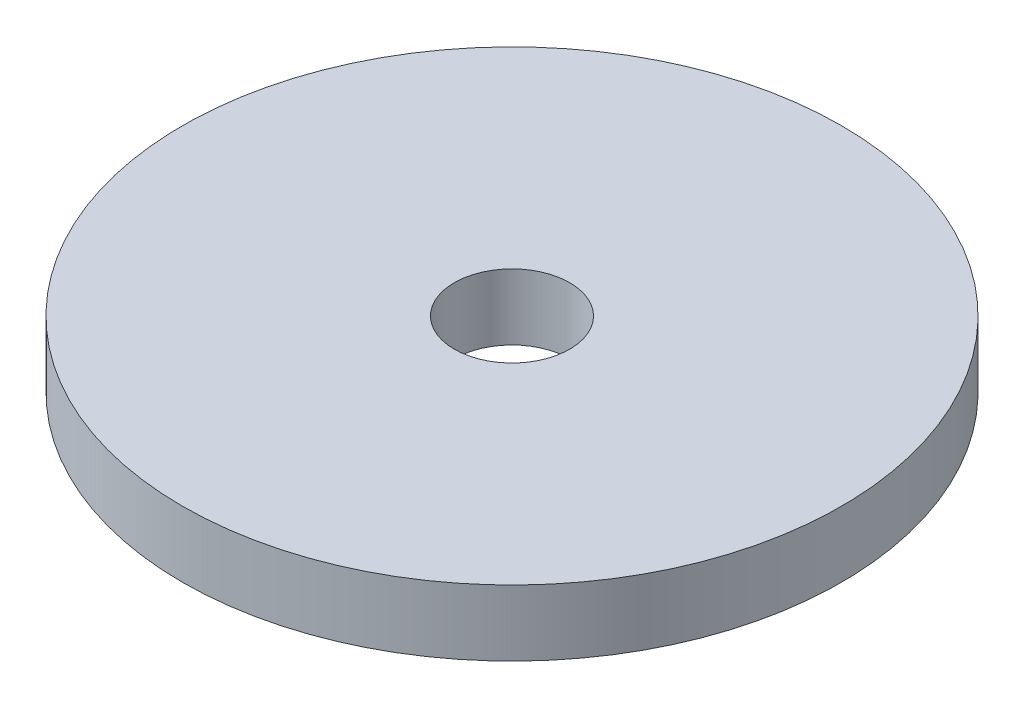
from build123d import *

# Parameters (mm, degrees)
SKETCH2_R           = 10
SKETCH2_R_2         = 1.75
BOSS_EXTRUDE1_DEPTH = 2


with BuildPart() as part:
    # Sketch2 → Boss-Extrude1 (new body)
    with BuildSketch(Plane(origin=(0, 0, 0), x_dir=(1, 0, 0), z_dir=(0, 1, 0))):
        Circle(SKETCH2_R)
        Circle(SKETCH2_R_2, mode=Mode.SUBTRACT)
    extrude(amount=BOSS_EXTRUDE1_DEPTH)


solid = part.part
